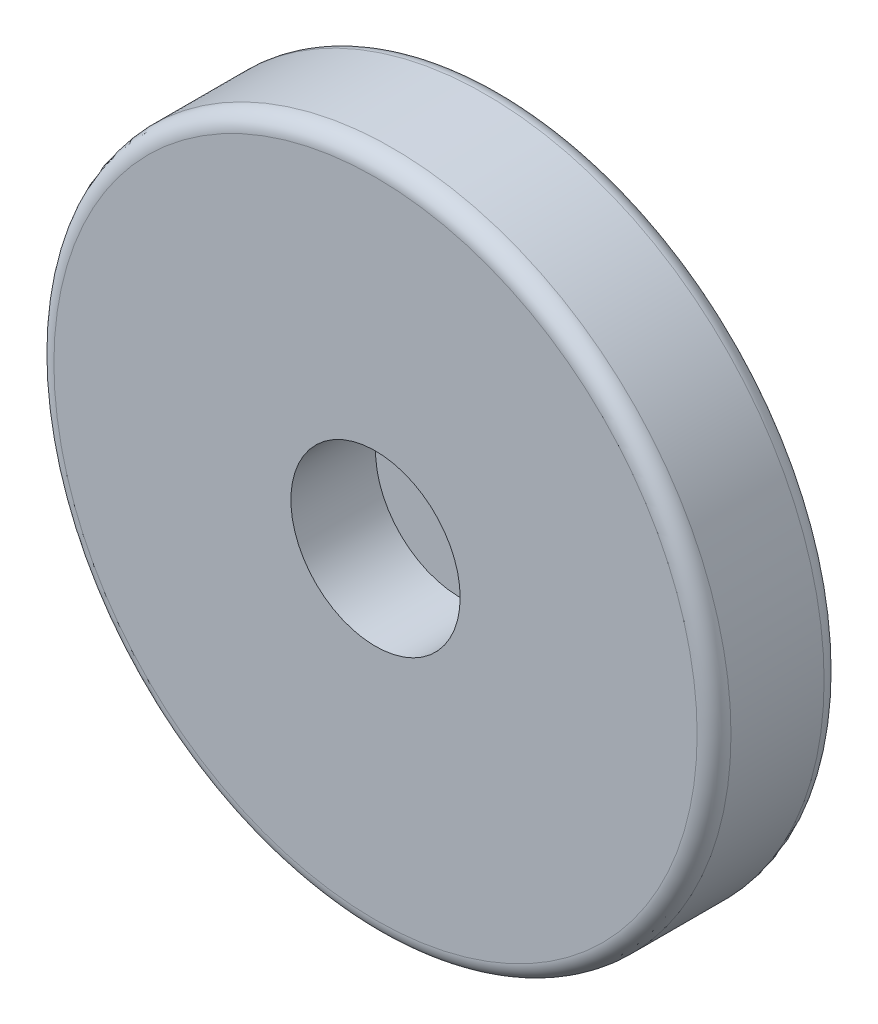
from build123d import *

# Parameters (mm, degrees)
SKETCH1_R          = 101.6
WHEEL_DEPTH        = 19.05
FILLET1_R          = 5.08
SKETCH2_R          = 25.4
CUT_EXTRUDE1_DEPTH = 25.4


with BuildPart() as part:
    # Sketch1 → Wheel (new body, symmetric)
    with BuildSketch(Plane.XY):
        Circle(SKETCH1_R)
    extrude(amount=WHEEL_DEPTH, both=True)

    # Fillet1
    fillet1_edges = [part.edges().sort_by_distance(p)[0] for p in [
        (-101.6, 0, -19.05),
        (-101.6, 0, 19.05),
    ]]
    fillet(fillet1_edges, radius=FILLET1_R)

    # Sketch2 → Cut-Extrude1 (cut)
    with BuildSketch(Plane.XY.offset(19.05)):
        Circle(SKETCH2_R)
    extrude(amount=-CUT_EXTRUDE1_DEPTH, mode=Mode.SUBTRACT)


solid = part.part
